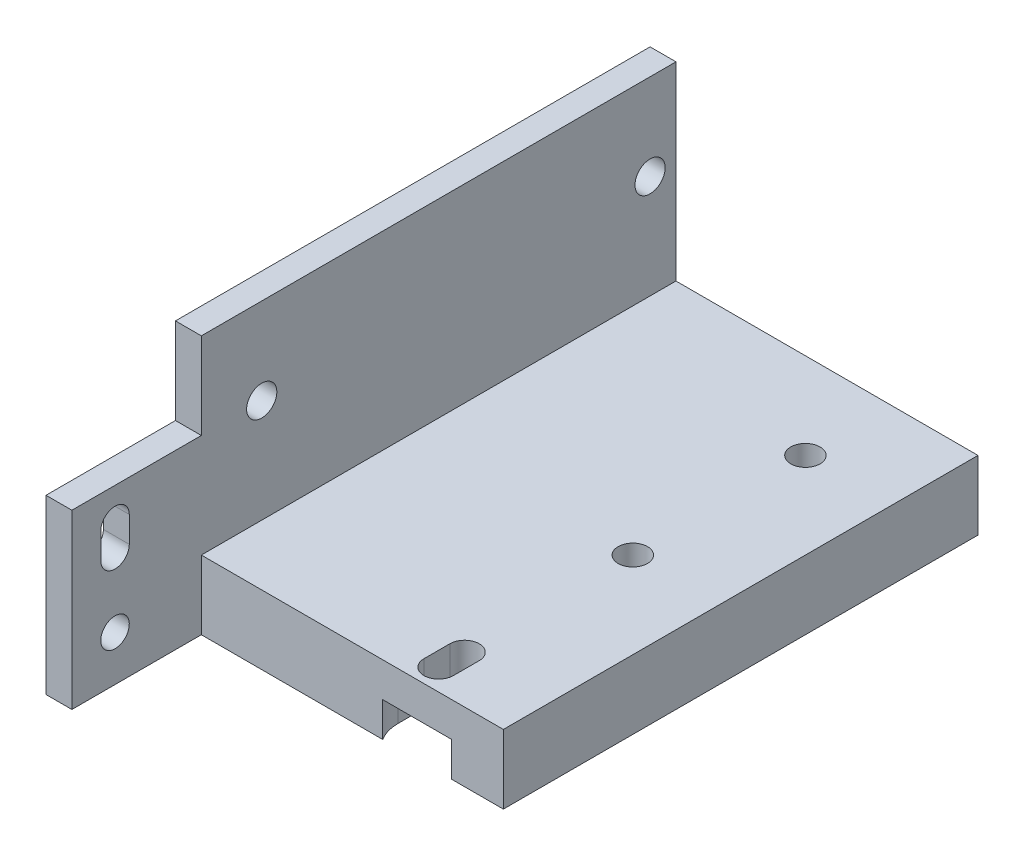
from build123d import *

# Parameters (mm, degrees)
RESSALTO_EXTRUS_O1_DEPTH = 55
ESBO_O2_W                = 15.2
ESBO_O2_H                = 25.2
CORTE_EXTRUS_O1_DEPTH    = 3
ESBO_O4_R                = 1.7
CORTE_EXTRUS_O2_DEPTH    = 31
ESBO_O5_R                = 4.7
CORTE_EXTRUS_O3_DEPTH    = 4
ESBO_O6_R                = 1.75
CORTE_EXTRUS_O4_DEPTH    = 4
ESBO_O7_W                = 15
ESBO_O7_H                = 20
ESBO_O7_R                = 1.65
RESSALTO_EXTRUS_O2_DEPTH = 3


with BuildPart() as part:
    # Esboço1 → Ressalto-extrusão1 (new body)
    with BuildSketch(Plane.XY):
        Polygon((0, 0), (38, 0), (38, 8), (3, 8), (3, 30), (0, 30), align=None)
    extrude(amount=RESSALTO_EXTRUS_O1_DEPTH)

    # Esboço2 → Corte-extrusão1 (cut)
    with BuildSketch(Plane.XZ):
        with Locations((28, 30)):
            Rectangle(ESBO_O2_W, ESBO_O2_H)
    extrude(amount=-CORTE_EXTRUS_O1_DEPTH, mode=Mode.SUBTRACT)

    # Esboço4 → Corte-extrusão2 (cut, through all)
    with BuildSketch(Plane.XZ):
        with Locations((28, 30)):
            Circle(ESBO_O4_R)
        with Locations((28, 10)):
            Circle(ESBO_O4_R)
        with BuildLine():
            Line((29.7, 52.5), (29.7, 49.5))
            ThreePointArc((29.7, 49.5), (28, 47.8), (26.3, 49.5))
            Line((26.3, 49.5), (26.3, 52.5))
            ThreePointArc((26.3, 52.5), (28, 54.2), (29.7, 52.5))
        make_face()
    extrude(amount=-CORTE_EXTRUS_O2_DEPTH, mode=Mode.SUBTRACT)

    # Esboço5 → Corte-extrusão3 (cut)
    with BuildSketch(Plane.XZ):
        with Locations((28, 10)):
            Circle(ESBO_O5_R)
        with BuildLine():
            Line((32.7, 49.5), (32.7, 52.5))
            ThreePointArc((32.7, 52.5), (28, 57.2), (23.3, 52.5))
            Line((23.3, 52.5), (23.3, 49.5))
            ThreePointArc((23.3, 49.5), (28, 44.8), (32.7, 49.5))
        make_face()
    extrude(amount=-CORTE_EXTRUS_O3_DEPTH, mode=Mode.SUBTRACT)

    # Esboço6 → Corte-extrusão4 (cut)
    with BuildSketch(Plane.ZY):
        with Locations((48, 20)):
            Circle(ESBO_O6_R)
        with Locations((3, 20)):
            Circle(ESBO_O6_R)
    extrude(amount=-CORTE_EXTRUS_O4_DEPTH, mode=Mode.SUBTRACT)

    # Esboço7 → Ressalto-extrusão2 (add)
    with BuildSketch(Plane.ZY):
        with Locations((62.5, 10)):
            Rectangle(ESBO_O7_W, ESBO_O7_H)
        with Locations((65, 5.25)):
            Circle(ESBO_O7_R, mode=Mode.SUBTRACT)
        with BuildLine():
            Line((63.35, 13.25), (63.35, 16.25))
            ThreePointArc((63.35, 16.25), (65, 17.9), (66.65, 16.25))
            Line((66.65, 16.25), (66.65, 13.25))
            ThreePointArc((66.65, 13.25), (65, 11.6), (63.35, 13.25))
        make_face(mode=Mode.SUBTRACT)
    extrude(amount=-RESSALTO_EXTRUS_O2_DEPTH)


solid = part.part
